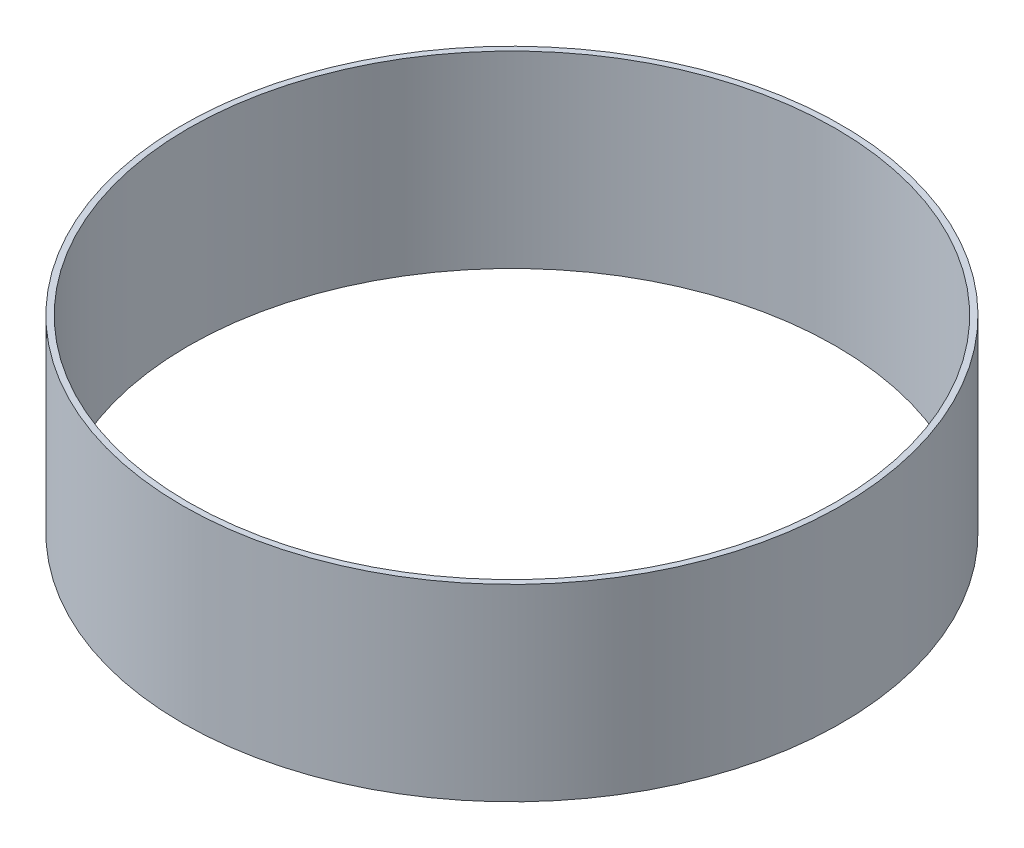
from build123d import *

# Parameters (mm, degrees)
SKETCH1_R           = 177.8
SKETCH1_R_2         = 174.625
BOSS_EXTRUDE1_DEPTH = 101.6


with BuildPart() as part:
    # Sketch1 → Boss-Extrude1 (new body)
    with BuildSketch(Plane(origin=(0, 0, 0), x_dir=(1, 0, 0), z_dir=(0, 1, 0))):
        Circle(SKETCH1_R)
        Circle(SKETCH1_R_2, mode=Mode.SUBTRACT)
    extrude(amount=BOSS_EXTRUDE1_DEPTH)


solid = part.part
